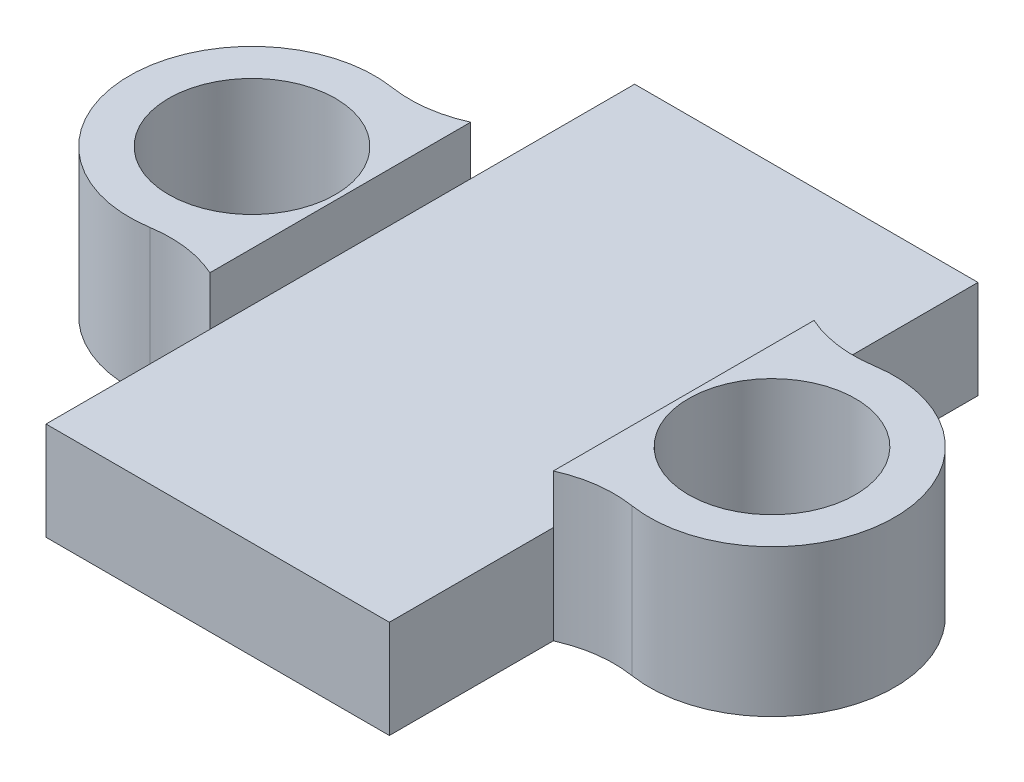
from build123d import *
from build123d.topology import SkipClean

# Parameters (mm, degrees)
CROQUIS1_R              = 1.7
SALIENTE_EXTRUIR1_DEPTH = 2
CROQUIS5_R              = 1.7
BOSS_EXTRUDE1_DEPTH     = 1


with BuildPart() as part:
    # Croquis1 → Saliente-Extruir1 (new body)
    with BuildSketch(Plane(origin=(0, 0, 0), x_dir=(1, 0, 0), z_dir=(0, 1, 0))):
        with BuildLine():
            Line((-3.5, 6), (3.5, 6))
            Line((3.5, 6), (3.5, 2.657498126))
            ThreePointArc((3.5, 2.657498126), (4.191822894, 2.460979566), (4.910964812, 2.469544821))
            ThreePointArc((4.910964812, 2.469544821), (7.8, 0), (4.910964812, -2.469544821))
            ThreePointArc((4.910964812, -2.469544821), (4.191822894, -2.460979566), (3.5, -2.657498126))
            Line((3.5, -2.657498126), (3.5, -6))
            Line((3.5, -6), (-3.5, -6))
            Line((-3.5, -6), (-3.5, -2.657498126))
            ThreePointArc((-3.5, -2.657498126), (-4.191822894, -2.460979566), (-4.910964812, -2.469544821))
            ThreePointArc((-4.910964812, -2.469544821), (-7.8, 0), (-4.910964812, 2.469544821))
            ThreePointArc((-4.910964812, 2.469544821), (-4.191822894, 2.460979566), (-3.5, 2.657498126))
            Line((-3.5, 2.657498126), (-3.5, 6))
        make_face()
        with Locations(Location((5.3, 0, 0), (0, 0, 270))):
            Circle(CROQUIS1_R, mode=Mode.SUBTRACT)
        with Locations(Location((-5.3, 0, 0), (0, 0, 90))):
            Circle(CROQUIS1_R, mode=Mode.SUBTRACT)
    extrude(amount=SALIENTE_EXTRUIR1_DEPTH)

    # Croquis5 → Boss-Extrude1 (add)
    with SkipClean():  # the faces are left unmerged after this step: merging them gives an invalid solid
        with BuildSketch(Plane(origin=(0, 2, 0), x_dir=(1, 0, 0), z_dir=(0, 1, 0))):
            with BuildLine():
                ThreePointArc((4.910964812, 2.469544821), (4.191822894, 2.460979566), (3.5, 2.657498126))
                Line((3.5, 2.657498126), (3.5, -2.657498126))
                ThreePointArc((3.5, -2.657498126), (4.191822894, -2.460979566), (4.910964812, -2.469544821))
                ThreePointArc((4.910964812, -2.469544821), (7.8, 0), (4.910964812, 2.469544821))
            make_face()
            with Locations((5.3, 0)):
                Circle(CROQUIS5_R, mode=Mode.SUBTRACT)
            with BuildLine():
                ThreePointArc((-4.910964812, -2.469544821), (-4.191822894, -2.460979566), (-3.5, -2.657498126))
                Line((-3.5, -2.657498126), (-3.5, 2.657498126))
                ThreePointArc((-3.5, 2.657498126), (-4.191822894, 2.460979566), (-4.910964812, 2.469544821))
                ThreePointArc((-4.910964812, 2.469544821), (-7.8, 0), (-4.910964812, -2.469544821))
            make_face()
            with Locations((-5.3, 0)):
                Circle(CROQUIS5_R, mode=Mode.SUBTRACT)
        extrude(amount=BOSS_EXTRUDE1_DEPTH)


solid = part.part
